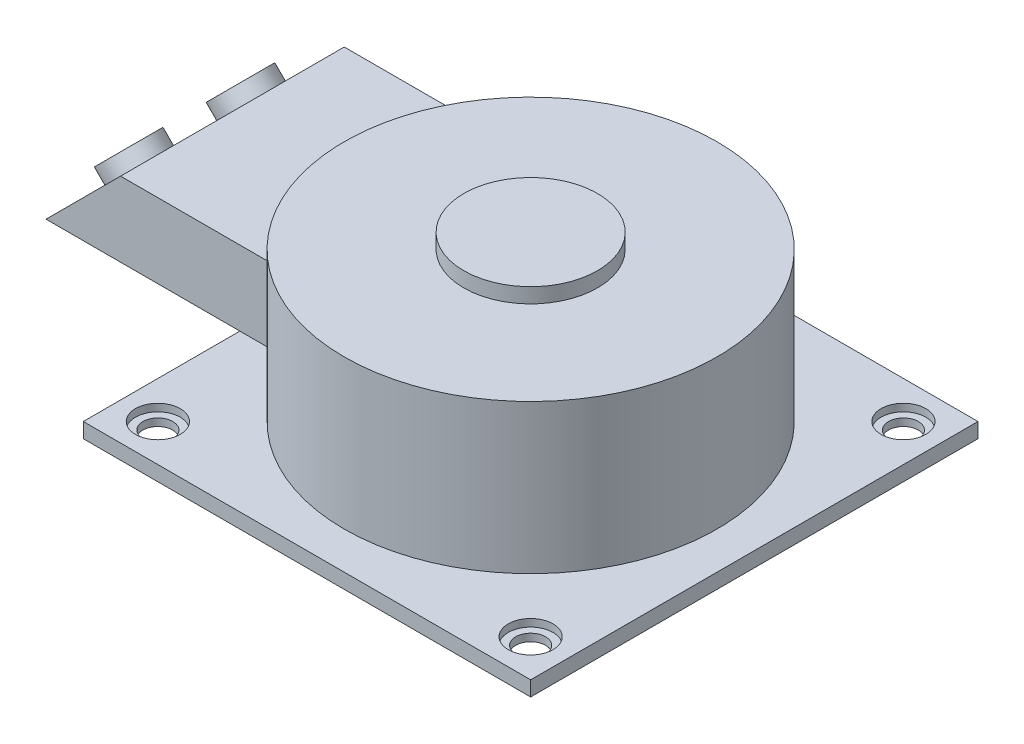
from build123d import *

# Parameters (mm, degrees)
SKETCH_1_W               = 300
SKETCH_1_H               = 300
EXTRUDE_1_DEPTH          = 10
SKETCH_2_R               = 125
EXTRUDE_2_DEPTH          = 100
SKETCH_3_W               = 150
SKETCH_3_H               = 50
EXTRUDE_3_DEPTH          = 200
DRAFT_3_ANGLE            = 45
SKETCH_5_R               = 18.8
EXTRUDE_5_DEPTH          = 10
SKETCH_6_R               = 44.85
EXTRUDE_6_DEPTH          = 10
SKETCH_7_R               = 15
CUT_EXTRUDE_1_DEPTH      = 5
SKETCH_8_R               = 10
CUT_EXTRUDE_2_DEPTH      = 25
MIRROR_2_COPY_1_SKETCH_R = 15
MIRROR_2_COPY_1_DEPTH    = 5
MIRROR_2_COPY_2_SKETCH_R = 10
MIRROR_2_COPY_2_DEPTH    = 25


with BuildPart() as part:
    # 草图1 → 凸台-拉伸1 (new body)
    with BuildSketch(Plane(origin=(0, 0, 0), x_dir=(1, 0, 0), z_dir=(0, 1, 0))):
        Rectangle(SKETCH_1_W, SKETCH_1_H)
    extrude(amount=EXTRUDE_1_DEPTH)

    # 草图2 → 凸台-拉伸2 (add)
    with BuildSketch(Plane(origin=(0, 10, 0), x_dir=(1, 0, 0), z_dir=(0, 1, 0))):
        Circle(SKETCH_2_R)
    extrude(amount=EXTRUDE_2_DEPTH)

    # 草图3 → 凸台-拉伸3 (add)
    with BuildSketch(Plane(origin=(0, 0, 0), x_dir=(0, 0, -1), z_dir=(1, 0, 0))):
        with Locations((0, 65)):
            Rectangle(SKETCH_3_W, SKETCH_3_H)
    extrude(amount=-EXTRUDE_3_DEPTH)

    # 拔模3
    draft_3_faces = [part.faces().sort_by_distance(p)[0] for p in [
        (-200, 65, 0),
    ]]
    draft(draft_3_faces, Plane(origin=(-200, 90, 75), x_dir=(0, 0, 1), z_dir=(0, 1, 0)), DRAFT_3_ANGLE)

    # 草图5 → 凸台-拉伸5 (add)
    with BuildSketch(Plane(origin=(-145, 145, 0), x_dir=(0, 0, 1), z_dir=(-0.707106781, 0.707106781, 0))):
        with Locations((-37.5, -113.13708499)):
            Circle(SKETCH_5_R)
        with Locations((37.5, -113.13708499)):
            Circle(SKETCH_5_R)
    extrude(amount=EXTRUDE_5_DEPTH)

    # 草图6 → 凸台-拉伸6 (add)
    with BuildSketch(Plane(origin=(0, 110, 0), x_dir=(1, 0, 0), z_dir=(0, 1, 0))):
        Circle(SKETCH_6_R)
    extrude(amount=EXTRUDE_6_DEPTH)

    # 草图7 → 切除-拉伸1 (cut)
    with BuildSketch(Plane(origin=(0, 10, 0), x_dir=(1, 0, 0), z_dir=(0, 1, 0))):
        with Locations((-125, 125)):
            Circle(SKETCH_7_R)
    cut_extrude_1 = extrude(amount=-CUT_EXTRUDE_1_DEPTH, mode=Mode.SUBTRACT)

    # 草图8 → 切除-拉伸2 (cut)
    with BuildSketch(Plane(origin=(0, 5, 0), x_dir=(1, 0, 0), z_dir=(0, 1, 0))):
        with Locations((-125, 125)):
            Circle(SKETCH_8_R)
    cut_extrude_2 = extrude(amount=-CUT_EXTRUDE_2_DEPTH, mode=Mode.SUBTRACT)

    # 镜向1: 切除-拉伸1, 切除-拉伸2 across plane
    add(cut_extrude_1.mirror(Plane.XY), mode=Mode.SUBTRACT)
    add(cut_extrude_2.mirror(Plane.XY), mode=Mode.SUBTRACT)

    # 镜向2: 切除-拉伸1, 切除-拉伸2 across plane
    add(cut_extrude_1.mirror(Plane(origin=(0, 0, 0), x_dir=(0, 0, 1), z_dir=(1, 0, 0))), mode=Mode.SUBTRACT)
    add(cut_extrude_2.mirror(Plane(origin=(0, 0, 0), x_dir=(0, 0, 1), z_dir=(1, 0, 0))), mode=Mode.SUBTRACT)

    # 镜向2 copy 1 sketch → 镜向2 copy 1 (cut)
    with BuildSketch(Plane(origin=(0, 10, 0), x_dir=(-1, 0, 0), z_dir=(0, 1, 0))):
        with Locations((-125, 125)):
            Circle(MIRROR_2_COPY_1_SKETCH_R)
    extrude(amount=-MIRROR_2_COPY_1_DEPTH, mode=Mode.SUBTRACT)

    # 镜向2 copy 2 sketch → 镜向2 copy 2 (cut)
    with BuildSketch(Plane(origin=(0, 5, 0), x_dir=(-1, 0, 0), z_dir=(0, 1, 0))):
        with Locations((-125, 125)):
            Circle(MIRROR_2_COPY_2_SKETCH_R)
    extrude(amount=-MIRROR_2_COPY_2_DEPTH, mode=Mode.SUBTRACT)


solid = part.part
